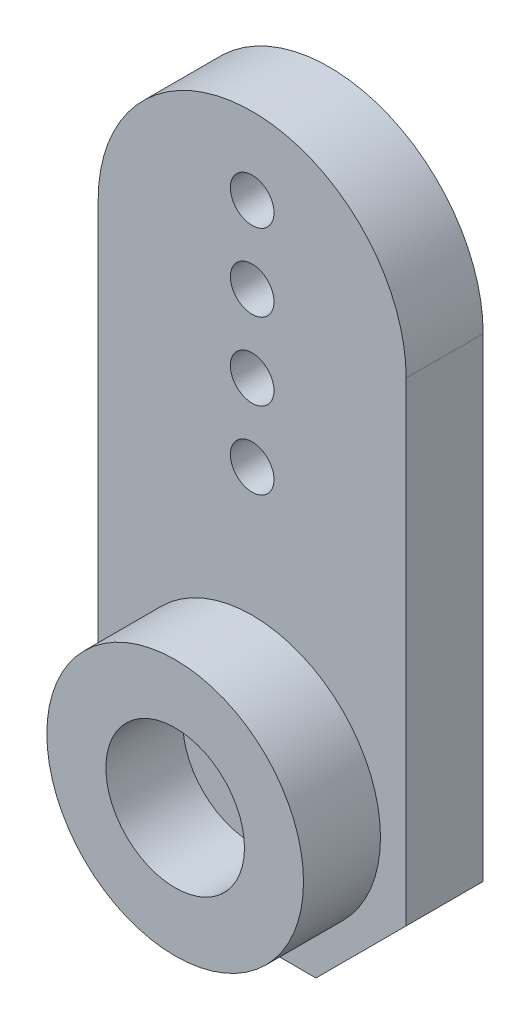
from build123d import *

# Parameters (mm, degrees)
SKETCH_1_R          = 1.35
SKETCH_1_R_2        = 0.85
EXTRUDE_1_DEPTH     = 3
SKETCH_2_R          = 5
SKETCH_2_R_2        = 2.7
EXTRUDE_2_DEPTH     = 3
SKETCH_3_R          = 3
CUT_EXTRUDE_1_DEPTH = 1.5


with BuildPart() as part:
    # Эскиз1 → Бобышка-Вытянуть1 (new body)
    with BuildSketch(Plane.XY):
        with BuildLine():
            Line((6, 16), (6, -2.485281374))
            Line((6, -2.485281374), (2.485281374, -6))
            Line((2.485281374, -6), (-2.485281374, -6))
            Line((-2.485281374, -6), (-6, -2.485281374))
            Line((-6, -2.485281374), (-6, 16))
            ThreePointArc((-6, 16), (0, 22), (6, 16))
        make_face()
        Circle(SKETCH_1_R, mode=Mode.SUBTRACT)
        with Locations((0, 10)):
            Circle(SKETCH_1_R_2, mode=Mode.SUBTRACT)
        with Locations((0, 13)):
            Circle(SKETCH_1_R_2, mode=Mode.SUBTRACT)
        with Locations((0, 16)):
            Circle(SKETCH_1_R_2, mode=Mode.SUBTRACT)
        with Locations((0, 19)):
            Circle(SKETCH_1_R_2, mode=Mode.SUBTRACT)
    extrude(amount=EXTRUDE_1_DEPTH)

    # Эскиз2 → Бобышка-Вытянуть2 (add)
    with BuildSketch(Plane.XY.offset(3)):
        Circle(SKETCH_2_R)
        Circle(SKETCH_2_R_2, mode=Mode.SUBTRACT)
    extrude(amount=EXTRUDE_2_DEPTH)

    # Эскиз3 → Вырез-Вытянуть1 (cut)
    with BuildSketch(Plane(origin=(0, 0, 0), x_dir=(-1, 0, 0), z_dir=(0, 0, -1))):
        Circle(SKETCH_3_R)
    extrude(amount=-CUT_EXTRUDE_1_DEPTH, mode=Mode.SUBTRACT)


solid = part.part
